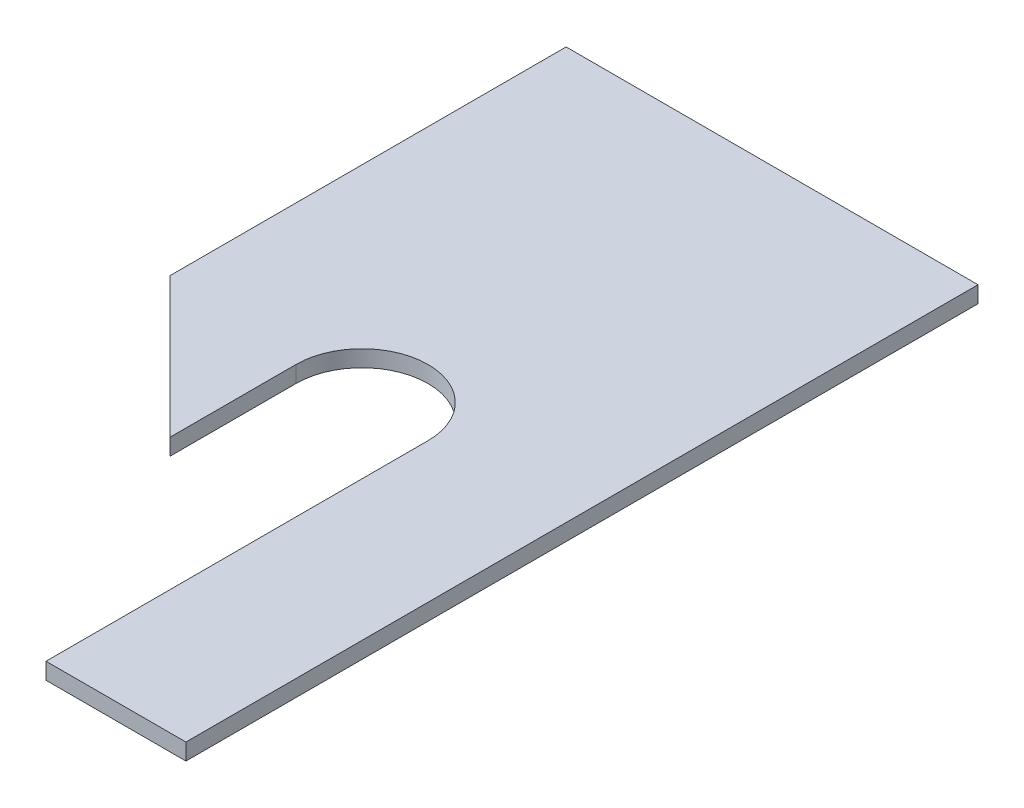
from build123d import *

# Parameters (mm, degrees)
SKETCH1_W               = 39.624
SKETCH1_H               = 63.5
BOSS_EXTRUDE1_DEPTH     = 1.5875
SKETCH2_W               = 39.624
SKETCH2_H               = 3.175
BOSS_EXTRUDE2_DEPTH     = 6.35
SKETCH3_R               = 6.35
CUT_EXTRUDE1_DEPTH      = 8.9375
CUT_EXTRUDE2_DEPTH      = 1
CUT_EXTRUDE2_DEPTH_BACK = 8.9375
SKETCH5_W               = 12.7
SKETCH5_H               = 28.946652836
CUT_EXTRUDE3_DEPTH      = 8.9375
SKETCH6_W               = 13.462
SKETCH6_H               = 12.7
BOSS_EXTRUDE3_DEPTH     = 1.5875
SKETCH7_W               = 7.112
SKETCH7_H               = 6.35
CUT_EXTRUDE4_DEPTH      = 77.2
FILLET1_R               = 3.175
F_4_CLEARANCE_HOLE1_D   = 2.9464
SKETCH10_R              = 2.38125
CUT_EXTRUDE5_DEPTH      = 74.025


with BuildPart() as part:
    # Sketch1 → Boss-Extrude1 (new body)
    with BuildSketch(Plane(origin=(0, 0, 0), x_dir=(1, 0, 0), z_dir=(0, 1, 0))):
        with Locations((0, -31.75)):
            Rectangle(SKETCH1_W, SKETCH1_H)
    extrude(amount=BOSS_EXTRUDE1_DEPTH)

    # Sketch2 → Boss-Extrude2 (add)
    with BuildSketch(Plane.XZ):
        with Locations((0, 1.5875)):
            Rectangle(SKETCH2_W, SKETCH2_H)
    extrude(amount=BOSS_EXTRUDE2_DEPTH)

    # Sketch3 → Cut-Extrude1 (cut, through all)
    with BuildSketch(Plane(origin=(10.289309191, 1.5875, 36.06936054), x_dir=(1, 0, 0), z_dir=(0, 1, 0))):
        with Locations((-10.289309191, -3.379645711)):
            Circle(SKETCH3_R)
    extrude(amount=-CUT_EXTRUDE1_DEPTH, mode=Mode.SUBTRACT)

    # Sketch4 → Cut-Extrude2 (cut, two sides)
    with BuildSketch(Plane(origin=(0, 1.5875, 0), x_dir=(1, 0, 0), z_dir=(0, 1, 0))) as cut_extrude2_sk:
        Polygon((-19.812, -38.1), (5.588, -63.5), (-19.812, -63.5), align=None)
    extrude(amount=CUT_EXTRUDE2_DEPTH, mode=Mode.SUBTRACT)
    extrude(cut_extrude2_sk.sketch, amount=-CUT_EXTRUDE2_DEPTH_BACK, mode=Mode.SUBTRACT)

    # Sketch5 → Cut-Extrude3 (cut, through all)
    with BuildSketch(Plane(origin=(0, 1.5875, 0), x_dir=(1, 0, 0), z_dir=(0, 1, 0))):
        with Locations((0, -53.922332669)):
            Rectangle(SKETCH5_W, SKETCH5_H)
    extrude(amount=-CUT_EXTRUDE3_DEPTH, mode=Mode.SUBTRACT)

    # Sketch6 → Boss-Extrude3 (add)
    with BuildSketch(Plane(origin=(0, 1.5875, 0), x_dir=(1, 0, 0), z_dir=(0, 1, 0))):
        with Locations((13.081, -69.85)):
            Rectangle(SKETCH6_W, SKETCH6_H)
    extrude(amount=-BOSS_EXTRUDE3_DEPTH)

    # Sketch7 → Cut-Extrude4 (cut, through all)
    with BuildSketch(Plane(origin=(0, 0, 0), x_dir=(-1, 0, 0), z_dir=(0, 0, -1))):
        with Locations((-16.256, -3.175)):
            Rectangle(SKETCH7_W, SKETCH7_H)
        with Locations((16.256, -3.175)):
            Rectangle(SKETCH7_W, SKETCH7_H)
    extrude(amount=-CUT_EXTRUDE4_DEPTH, mode=Mode.SUBTRACT)

    # Fillet1
    fillet1_edges = [part.edges().sort_by_distance(p)[0] for p in [
        (-12.7, 0, 1.5875),
        (0, 0, 3.175),
        (12.7, 0, 1.5875),
    ]]
    fillet(fillet1_edges, radius=FILLET1_R)

    # #4 Clearance Hole1 (through all)
    with Locations(Plane(origin=(0, 0, 0), x_dir=(-1, 0, 0), z_dir=(0, 0, -1))):
        with Locations((-9.525, -3.175), (9.525, -3.175)):
            Hole(F_4_CLEARANCE_HOLE1_D / 2)

    # Sketch10 → Cut-Extrude5 (cut, through all)
    with BuildSketch(Plane.XY.offset(3.175)):
        with Locations((9.525, -3.175)):
            Circle(SKETCH10_R)
        with Locations((-9.525, -3.175)):
            Circle(SKETCH10_R)
    extrude(amount=CUT_EXTRUDE5_DEPTH, mode=Mode.SUBTRACT)


solid = part.part
